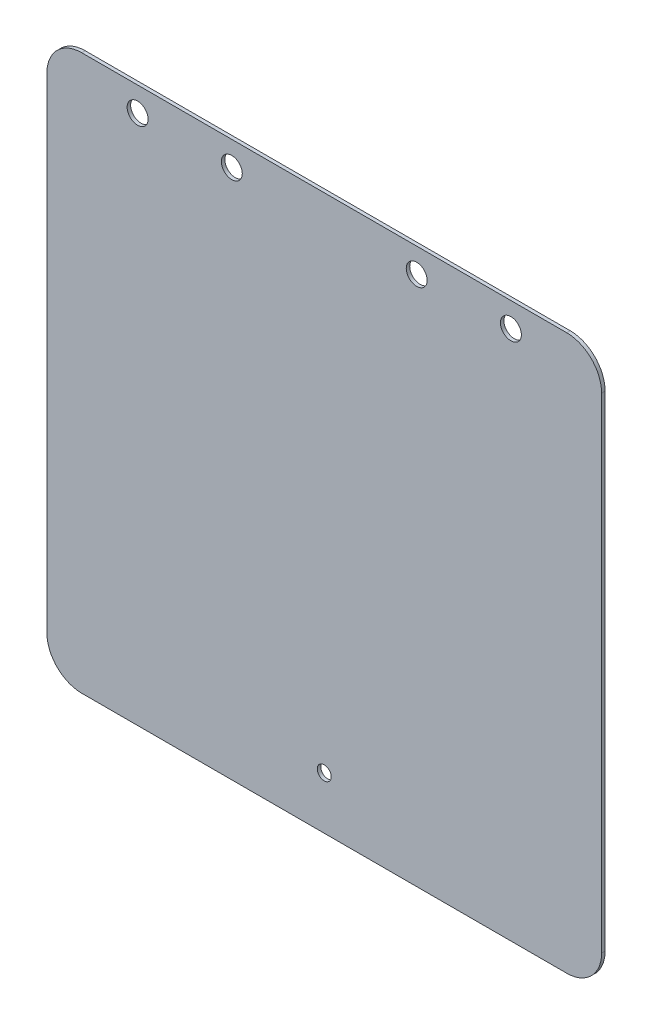
from build123d import *

# Parameters (mm, degrees)
EXTRUDE_1_DEPTH     = 1
SKETCH_2_R          = 3
CUT_EXTRUDE_1_DEPTH = 1
SKETCH_3_R          = 2
CUT_EXTRUDE_2_DEPTH = 1


with BuildPart() as part:
    # 스케치1 → 보스-돌출1 (new body)
    with BuildSketch(Plane.XY):
        with BuildLine():
            Line((-69.5, -79.5), (69.5, -79.5))
            ThreePointArc((69.5, -79.5), (76.571067812, -76.571067812), (79.5, -69.5))
            Line((79.5, -69.5), (79.5, 69.5))
            ThreePointArc((79.5, 69.5), (76.571067812, 76.571067812), (69.5, 79.5))
            Line((69.5, 79.5), (-69.5, 79.5))
            ThreePointArc((-69.5, 79.5), (-76.571067812, 76.571067812), (-79.5, 69.5))
            Line((-79.5, 69.5), (-79.5, -69.5))
            ThreePointArc((-79.5, -69.5), (-76.571067812, -76.571067812), (-69.5, -79.5))
        make_face()
    extrude(amount=EXTRUDE_1_DEPTH)

    # 스케치2 → 컷-돌출1 (cut)
    with BuildSketch(Plane.XY.offset(1)):
        with Locations((-53.5, 72.5)):
            Circle(SKETCH_2_R)
        with Locations((-26.5, 72.5)):
            Circle(SKETCH_2_R)
        with Locations((26.5, 72.5)):
            Circle(SKETCH_2_R)
        with Locations((53.5, 72.5)):
            Circle(SKETCH_2_R)
    extrude(amount=-CUT_EXTRUDE_1_DEPTH, mode=Mode.SUBTRACT)

    # 스케치3 → 컷-돌출2 (cut)
    with BuildSketch(Plane.XY.offset(1)):
        with Locations((0, -64.5)):
            Circle(SKETCH_3_R)
    extrude(amount=-CUT_EXTRUDE_2_DEPTH, mode=Mode.SUBTRACT)


solid = part.part
